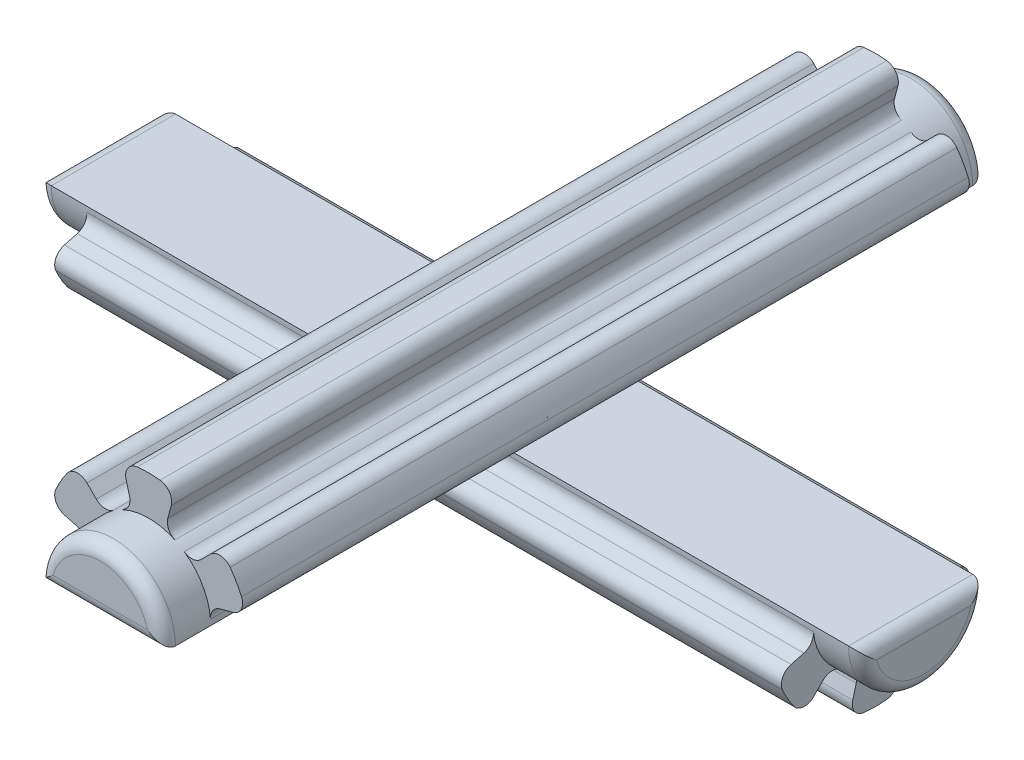
from build123d import *

# Parameters (mm, degrees)
BOSS_EXTRUDE9_START  = 1.85
BOSS_EXTRUDE9_DEPTH  = 31.5
BOSS_EXTRUDE10_DEPTH = 27.8
FILLET4_R            = 0.5
BOSS_EXTRUDE11_DEPTH = 31.5
BOSS_EXTRUDE12_START = -1.85
BOSS_EXTRUDE12_DEPTH = 27.8
FILLET5_R            = 0.5


with BuildPart() as part:
    # Sketch10 → Boss-Extrude9 (new body)
    with BuildSketch(Plane(origin=(13.899999999999999, 0, 0), x_dir=(0, 0, -1), z_dir=(1, 0, 0)).offset(BOSS_EXTRUDE9_START)):
        with BuildLine():
            Line((2.375, 0), (-2.375, 0))
            ThreePointArc((-2.375, 0), (-2.3546815457628005, -0.30999970652261516), (-2.2940738374365415, -0.6146952321184724))
            ThreePointArc((-2.294073837436541, -0.6146952321184722), (-2.0568103339880484, -1.1874999999999882), (-1.679378605318059, -1.6793786053180417))
            ThreePointArc((-1.6793786053180593, -1.6793786053180415), (-1.1875000000000056, -2.0568103339880377), (-0.614695232118488, -2.294073837436537))
            ThreePointArc((-0.6146952321184879, -2.294073837436537), (8e-16, -2.375), (0.6146952321184889, -2.2940738374365366))
            ThreePointArc((0.6146952321184891, -2.2940738374365366), (1.1874999999999993, -2.0568103339880426), (1.6793786053180475, -1.679378605318053))
            ThreePointArc((1.679378605318047, -1.6793786053180533), (2.0568103339880404, -1.1875000000000027), (2.2940738374365366, -0.6146952321184884))
            ThreePointArc((2.294073837436536, -0.6146952321184882), (2.3546815457627996, -0.30999970652262326), (2.374999999999999, 1.5e-16))
        make_face()
    extrude(amount=-BOSS_EXTRUDE9_DEPTH)

    # Sketch10_3 → Boss-Extrude10 (add)
    with BuildSketch(Plane(origin=(13.899999999999999, 0, 0), x_dir=(0, 0, -1), z_dir=(1, 0, 0))):
        with BuildLine():
            ThreePointArc((-1.679378605318059, -1.6793786053180417), (-2.0568103339880484, -1.1874999999999882), (-2.294073837436541, -0.6146952321184722))
            Line((-2.294073837436541, -0.6146952321184723), (-3.7429625768701458, -1.002923799772244))
            ThreePointArc((-3.7429625768701453, -1.002923799772244), (-3.3558484396647104, -1.937499999999981), (-2.7400387770978853, -2.740038777097858))
            Line((-2.740038777097886, -2.740038777097858), (-1.6793786053180595, -1.6793786053180415))
        make_face()
        with BuildLine():
            Line((3.742962576870139, -1.0029237997722704), (2.2940738374365366, -0.6146952321184883))
            ThreePointArc((2.2940738374365366, -0.6146952321184884), (2.0568103339880404, -1.1875000000000027), (1.679378605318047, -1.6793786053180533))
            Line((1.6793786053180473, -1.6793786053180535), (2.740038777097866, -2.740038777097877))
            ThreePointArc((2.740038777097866, -2.7400387770978774), (3.3558484396646966, -1.937500000000004), (3.7429625768701396, -1.0029237997722706))
        make_face()
        with BuildLine():
            ThreePointArc((0.6146952321184889, -2.2940738374365366), (8e-16, -2.375), (-0.6146952321184879, -2.294073837436537))
            Line((-0.6146952321184881, -2.294073837436537), (-1.00292379977227, -3.7429625768701387))
            ThreePointArc((-1.0029237997722702, -3.7429625768701396), (9.4e-16, -3.874999999999999), (1.0029237997722722, -3.7429625768701387))
            Line((1.0029237997722715, -3.7429625768701382), (0.614695232118489, -2.2940738374365366))
        make_face()
    extrude(amount=-BOSS_EXTRUDE10_DEPTH)

    # Fillet4
    fillet4_edges = [part.edges().sort_by_distance(p)[0] for p in [
        (-15.75, 0, 0),
        (-15.75, -2.375000000000048, -5.294e-14),
        (15.749999999999998, 0, 0),
        (15.749999999999998, -2.3749999999999236, -8.83e-14),
        (-1.78e-15, -0.6146952321184884, -2.2940738374365366),
        (-1.78e-15, -1.0029237997722706, -3.7429625768701396),
        (-1.78e-15, -2.740038777097877, -2.7400387770978663),
        (-1.78e-15, -1.6793786053180533, -1.6793786053180475),
        (-1.78e-15, -2.2940738374365366, -0.6146952321184889),
        (-1.78e-15, -3.7429625768701387, -1.002923799772272),
        (-1.78e-15, -3.7429625768701396, 1.0029237997722702),
        (-1.78e-15, -2.294073837436537, 0.614695232118488),
        (-1.78e-15, -1.6793786053180417, 1.6793786053180595),
        (-1.78e-15, -2.740038777097858, 2.740038777097886),
        (-1.78e-15, -0.6146952321184724, 2.2940738374365415),
        (-1.78e-15, -1.002923799772244, 3.7429625768701458),
    ]]
    fillet(fillet4_edges, radius=FILLET4_R)


with BuildPart() as body_2:
    # Sketch12 → Boss-Extrude11 (new body)
    with BuildSketch(Plane.XY.offset(15.75)):
        with BuildLine():
            ThreePointArc((-2.2940738374365424, 0.6146952321184705), (-2.3546815457628014, 0.3099997065226141), (-2.375, 1e-17))
            Line((-2.375, 0), (2.375, 0))
            ThreePointArc((2.375, 0), (2.354681545762799, 0.30999970652261893), (2.2940738374365393, 0.61469523211848))
            ThreePointArc((2.2940738374365397, 0.6146952321184802), (2.056810333988045, 1.1874999999999953), (1.6793786053180533, 1.679378605318048))
            ThreePointArc((1.6793786053180533, 1.679378605318048), (1.1875000000000027, 2.0568103339880413), (0.614695232118488, 2.294073837436537))
            ThreePointArc((0.6146952321184886, 2.2940738374365366), (-2.2e-16, 2.375), (-0.6146952321184889, 2.294073837436537))
            ThreePointArc((-0.6146952321184889, 2.294073837436537), (-1.187500000000007, 2.0568103339880386), (-1.67937860531806, 1.6793786053180408))
            ThreePointArc((-1.6793786053180595, 1.6793786053180408), (-2.0568103339880497, 1.1874999999999862), (-2.2940738374365415, 0.61469523211847))
        make_face()
    extrude(amount=-BOSS_EXTRUDE11_DEPTH)

    # Sketch12_3 → Boss-Extrude12 (add)
    with BuildSketch(Plane.XY.offset(15.75).offset(BOSS_EXTRUDE12_START)):
        with BuildLine():
            Line((-3.742962576870146, 1.0029237997722413), (-2.294073837436542, 0.6146952321184705))
            ThreePointArc((-2.2940738374365415, 0.61469523211847), (-2.0568103339880497, 1.1874999999999862), (-1.6793786053180595, 1.6793786053180408))
            Line((-1.67937860531806, 1.6793786053180408), (-2.7400387770978876, 2.740038777097856))
            ThreePointArc((-2.7400387770978876, 2.7400387770978565), (-3.3558484396647126, 1.9374999999999782), (-3.7429625768701467, 1.0029237997722413))
        make_face()
        with BuildLine():
            ThreePointArc((1.6793786053180533, 1.679378605318048), (2.056810333988045, 1.1874999999999953), (2.2940738374365397, 0.6146952321184802))
            Line((2.2940738374365393, 0.6146952321184801), (3.742962576870143, 1.002923799772257))
            ThreePointArc((3.742962576870143, 1.0029237997722573), (3.3558484396647046, 1.9374999999999925), (2.740038777097876, 2.7400387770978676))
            Line((2.740038777097876, 2.740038777097867), (1.6793786053180533, 1.679378605318048))
        make_face()
        with BuildLine():
            Line((-1.0029237997722713, 3.742962576870139), (-0.6146952321184889, 2.294073837436537))
            ThreePointArc((-0.6146952321184889, 2.294073837436537), (-2.2e-16, 2.375), (0.6146952321184886, 2.2940738374365366))
            Line((0.6146952321184883, 2.294073837436537), (1.0029237997722704, 3.742962576870139))
            ThreePointArc((1.0029237997722706, 3.74296257687014), (-4.4e-16, 3.875), (-1.0029237997722715, 3.74296257687014))
        make_face()
    extrude(amount=-BOSS_EXTRUDE12_DEPTH)

    # Fillet5
    fillet5_edges = [body_2.edges().sort_by_distance(p)[0] for p in [
        (0, 0, -15.75),
        (-1.5212e-13, 2.3750000000001332, -15.75),
        (-2.154e-14, 2.3749999999999845, 15.75),
        (0, 0, 15.75),
        (2.2940738374365397, 0.6146952321184802, 0),
        (3.742962576870143, 1.0029237997722573, 0),
        (2.740038777097876, 2.740038777097867, 0),
        (1.6793786053180535, 1.679378605318048, 0),
        (0.6146952321184882, 2.2940738374365366, 0),
        (1.0029237997722706, 3.7429625768701396, 0),
        (-1.0029237997722715, 3.7429625768701396, 0),
        (-0.6146952321184889, 2.294073837436537, 0),
        (-2.7400387770978876, 2.7400387770978565, 0),
        (-1.6793786053180597, 1.6793786053180408, 0),
        (-2.294073837436542, 0.6146952321184704, 0),
        (-3.7429625768701467, 1.0029237997722418, 0),
    ]]
    fillet(fillet5_edges, radius=FILLET5_R)


solid = Compound([part.part, body_2.part])
